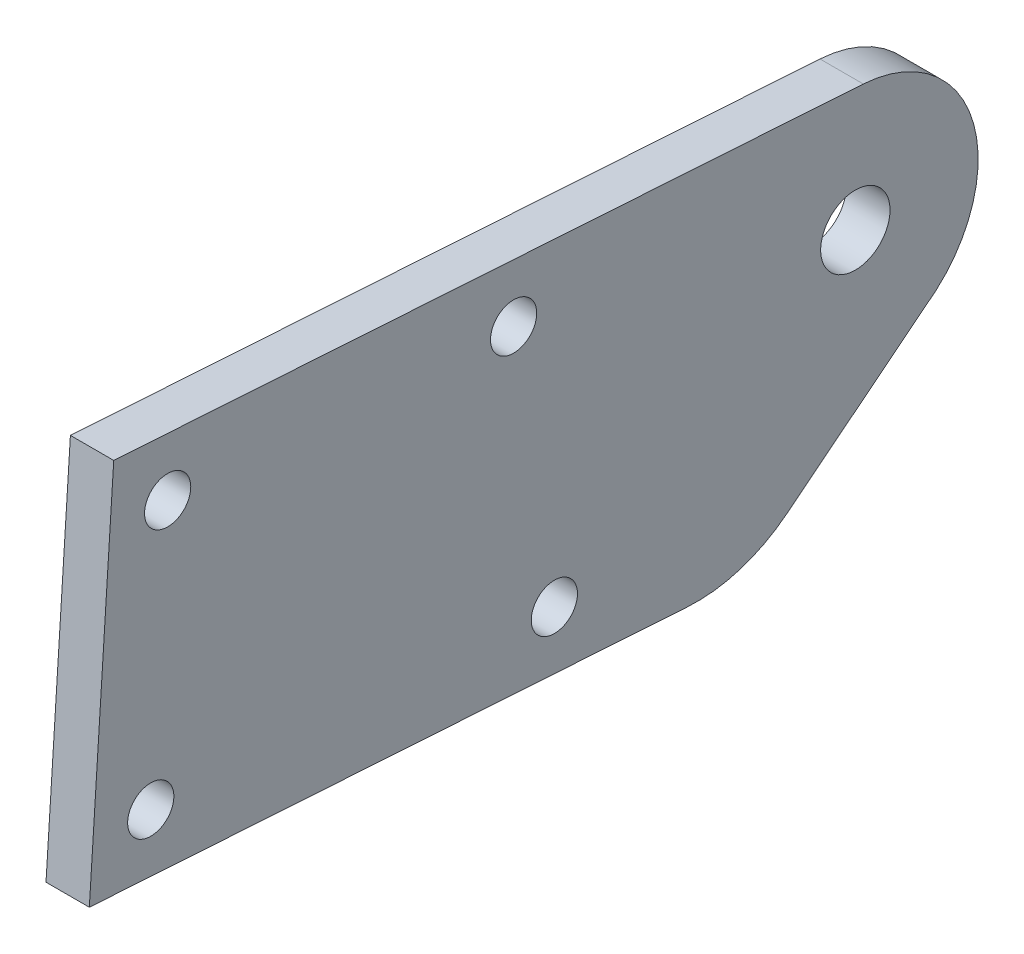
from build123d import *

# Parameters (mm, degrees)
SKETCH_1_R      = 2.4
SKETCH_1_R_2    = 1.6
EXTRUDE_1_DEPTH = 3


with BuildPart() as part:
    # 草图1 → 凸台-拉伸1 (new body)
    with BuildSketch(Plane(origin=(0, 0, 0), x_dir=(0, 0, -1), z_dir=(1, 0, 0))):
        with BuildLine():
            Line((-52.988376737, -14.191142444), (-11.576067608, -16.887557214))
            ThreePointArc((-11.576067608, -16.887557214), (-7.935716472, -16.451026673), (-4.697384878, -14.73174665))
            Line((-4.697384878, -14.73174665), (5.632436087, -6.506846665))
            ThreePointArc((5.632436087, -6.506846665), (8.08940986, 2.62041481), (0.591065641, 8.375278503))
            Line((0.591065641, 8.375278503), (-51.299056641, 11.753918697))
            Line((-51.299056641, 11.753918697), (-52.988376737, -14.191142444))
        make_face()
        with Locations((0.038787918, -0.106760716)):
            Circle(SKETCH_1_R, mode=Mode.SUBTRACT)
        with Locations((-47.567404172, 7.502475429)):
            Circle(SKETCH_1_R_2, mode=Mode.SUBTRACT)
        with Locations((-20.796098395, -12.278757773)):
            Circle(SKETCH_1_R_2, mode=Mode.SUBTRACT)
        with Locations((-23.618116965, 5.943103032)):
            Circle(SKETCH_1_R_2, mode=Mode.SUBTRACT)
        with Locations((-48.73693347, -10.459489976)):
            Circle(SKETCH_1_R_2, mode=Mode.SUBTRACT)
    extrude(amount=EXTRUDE_1_DEPTH)


solid = part.part
